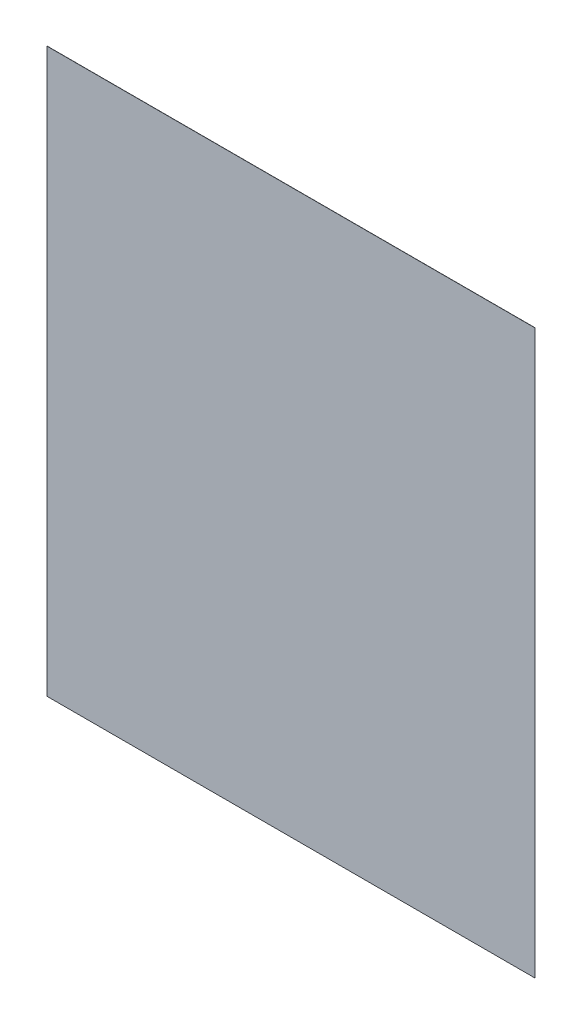
from build123d import *

# Parameters (mm, degrees)
SKETCH_1_W      = 260
SKETCH_1_H      = 300
EXTRUDE_1_DEPTH = 0.1


with BuildPart() as part:
    # Эскиз1 → Бобышка-Вытянуть1 (new body)
    with BuildSketch(Plane.XY):
        Rectangle(SKETCH_1_W, SKETCH_1_H)
    extrude(amount=EXTRUDE_1_DEPTH)


solid = part.part
